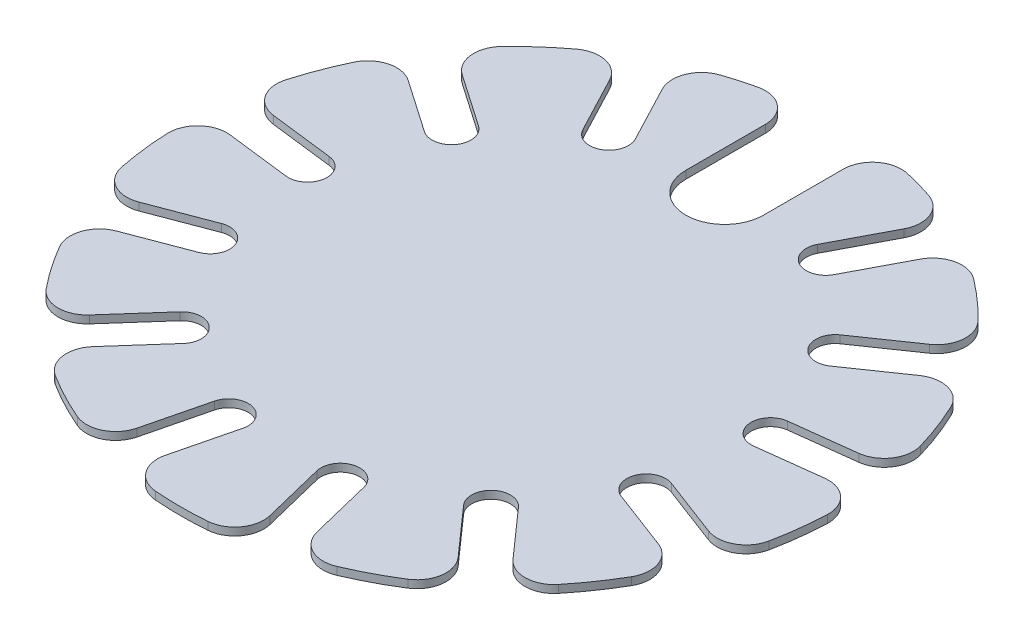
from build123d import *

# Parameters (mm, degrees)
BOSS_EXTRUDE1_DEPTH     = 0.1
CUT_EXTRUDE1_DEPTH      = 1.1
CUT_EXTRUDE1_DEPTH_BACK = 1.1
FILLET1_R               = 0.75


with BuildPart() as part:
    # Sketch1 → Boss-Extrude1 (new body, symmetric)
    with BuildSketch(Plane(origin=(0, 0, 0), x_dir=(1, 0, 0), z_dir=(0, 1, 0))):
        with BuildLine():
            Line((-0.5, 6), (-0.5, 8.485281374))
            ThreePointArc((-0.5, 8.485281374), (-2.034183146, 8.253005448), (-3.500578863, 7.745705108))
            Line((-3.500578863, 7.745705108), (-2.345611019, 5.54509774))
            ThreePointArc((-2.345611019, 5.54509774), (-2.555977446, 4.870008141), (-3.231067045, 5.080374568))
            Line((-3.231067045, 5.080374568), (-4.386034889, 7.280981936))
            ThreePointArc((-4.386034889, 7.280981936), (-5.636542595, 6.362341359), (-6.699217295, 5.231681148))
            Line((-6.699217295, 5.231681148), (-4.653870822, 3.819880413))
            ThreePointArc((-4.653870822, 3.819880413), (-4.526411262, 3.124356107), (-5.221935569, 2.996896547))
            Line((-5.221935569, 2.996896547), (-7.267282042, 4.408697282))
            ThreePointArc((-7.267282042, 4.408697282), (-7.947638063, 3.01414154), (-8.363145779, 1.519142085))
            Line((-8.363145779, 1.519142085), (-5.895984904, 1.219574519))
            ThreePointArc((-5.895984904, 1.219574519), (-5.459898808, 0.662951741), (-6.016521585, 0.226865644))
            Line((-6.016521585, 0.226865644), (-8.48368246, 0.526433211))
            ThreePointArc((-8.48368246, 0.526433211), (-8.43802543, -1.024561782), (-8.111178352, -2.541414122))
            Line((-8.111178352, -2.541414122), (-5.7873999, -1.660121201))
            ThreePointArc((-5.7873999, -1.660121201), (-5.142589335, -1.950326879), (-5.432795013, -2.595137444))
            Line((-5.432795013, -2.595137444), (-7.756573465, -3.476430365))
            ThreePointArc((-7.756573465, -3.476430365), (-6.99536286, -4.828550347), (-6.001037715, -6.019762981))
            Line((-6.001037715, -6.019762981), (-4.352991324, -4.15950316))
            ThreePointArc((-4.352991324, -4.15950316), (-3.64717462, -4.116809115), (-3.604480575, -4.822625818))
            Line((-3.604480575, -4.822625818), (-5.252526967, -6.682885639))
            ThreePointArc((-5.252526967, -6.682885639), (-3.950146962, -7.526376218), (-2.516131657, -8.119056687))
            Line((-2.516131657, -8.119056687), (-1.921364894, -5.705993072))
            ThreePointArc((-1.921364894, -5.705993072), (-1.316236154, -5.340179996), (-0.950423077, -5.945308737))
            Line((-0.950423077, -5.945308737), (-1.54518984, -8.358372351))
            ThreePointArc((-1.54518984, -8.358372351), (0, -8.5), (1.54518984, -8.358372351))
            Line((1.54518984, -8.358372351), (0.950423077, -5.945308737))
            ThreePointArc((0.950423077, -5.945308737), (1.316236154, -5.340179996), (1.921364894, -5.705993072))
            Line((1.921364894, -5.705993072), (2.516131657, -8.119056687))
            ThreePointArc((2.516131657, -8.119056687), (3.950146962, -7.526376218), (5.252526967, -6.682885639))
            Line((5.252526967, -6.682885639), (3.604480575, -4.822625818))
            ThreePointArc((3.604480575, -4.822625818), (3.64717462, -4.116809115), (4.352991324, -4.15950316))
            Line((4.352991324, -4.15950316), (6.001037715, -6.019762981))
            ThreePointArc((6.001037715, -6.019762981), (6.99536286, -4.828550347), (7.756573465, -3.476430365))
            Line((7.756573465, -3.476430365), (5.432795013, -2.595137444))
            ThreePointArc((5.432795013, -2.595137444), (5.142589335, -1.950326879), (5.7873999, -1.660121201))
            Line((5.7873999, -1.660121201), (8.111178352, -2.541414122))
            ThreePointArc((8.111178352, -2.541414122), (8.43802543, -1.024561782), (8.48368246, 0.526433211))
            Line((8.48368246, 0.526433211), (6.016521585, 0.226865644))
            ThreePointArc((6.016521585, 0.226865644), (5.459898808, 0.662951741), (5.895984904, 1.219574519))
            Line((5.895984904, 1.219574519), (8.363145779, 1.519142085))
            ThreePointArc((8.363145779, 1.519142085), (7.947638063, 3.01414154), (7.267282042, 4.408697282))
            Line((7.267282042, 4.408697282), (5.221935569, 2.996896547))
            ThreePointArc((5.221935569, 2.996896547), (4.526411262, 3.124356107), (4.653870822, 3.819880413))
            Line((4.653870822, 3.819880413), (6.699217295, 5.231681148))
            ThreePointArc((6.699217295, 5.231681148), (5.636542595, 6.362341359), (4.386034889, 7.280981936))
            Line((4.386034889, 7.280981936), (3.231067045, 5.080374568))
            ThreePointArc((3.231067045, 5.080374568), (2.555977446, 4.870008141), (2.345611019, 5.54509774))
            Line((2.345611019, 5.54509774), (3.500578863, 7.745705108))
            ThreePointArc((3.500578863, 7.745705108), (2.034183146, 8.253005448), (0.5, 8.485281374))
            Line((0.5, 8.485281374), (0.5, 6))
            ThreePointArc((0.5, 6), (0, 5.5), (-0.5, 6))
        make_face()
    extrude(amount=BOSS_EXTRUDE1_DEPTH, both=True)

    # Sketch2 → Cut-Extrude1 (cut, two sides)
    with BuildSketch(Plane(origin=(0, 0, 0), x_dir=(1, 0, 0), z_dir=(0, 1, 0))) as cut_extrude1_sk:
        with BuildLine():
            Line((-1, 5.5), (-1, 8.485281374))
            Line((-1, 8.485281374), (1, 8.485281374))
            Line((1, 8.485281374), (1, 5.5))
            ThreePointArc((1, 5.5), (0, 4.5), (-1, 5.5))
        make_face()
    extrude(amount=CUT_EXTRUDE1_DEPTH, mode=Mode.SUBTRACT)
    extrude(cut_extrude1_sk.sketch, amount=-CUT_EXTRUDE1_DEPTH_BACK, mode=Mode.SUBTRACT)

    # Fillet1
    fillet1_edges = [part.edges().sort_by_distance(p)[0] for p in [
        (-1, 0, -8.440971508),
        (1, 0, -8.440971508),
        (3.500578863, 0, -7.745705108),
        (4.386034889, 0, -7.280981936),
        (6.699217295, 0, -5.231681148),
        (7.267282042, 0, -4.408697282),
        (8.363145779, 0, -1.519142085),
        (8.48368246, 0, -0.526433211),
        (8.111178352, 0, 2.541414122),
        (7.756573465, 0, 3.476430365),
        (6.001037715, 0, 6.019762981),
        (5.252526967, 0, 6.682885639),
        (2.516131657, 0, 8.119056687),
        (1.54518984, 0, 8.358372351),
        (-1.54518984, 0, 8.358372351),
        (-2.516131657, 0, 8.119056687),
        (-5.252526967, 0, 6.682885639),
        (-6.001037715, 0, 6.019762981),
        (-7.756573465, 0, 3.476430365),
        (-8.111178352, 0, 2.541414122),
        (-8.48368246, 0, -0.526433211),
        (-8.363145779, 0, -1.519142085),
        (-7.267282042, 0, -4.408697282),
        (-6.699217295, 0, -5.231681148),
        (-4.386034889, 0, -7.280981936),
        (-3.500578863, 0, -7.745705108),
    ]]
    fillet(fillet1_edges, radius=FILLET1_R)


solid = part.part
